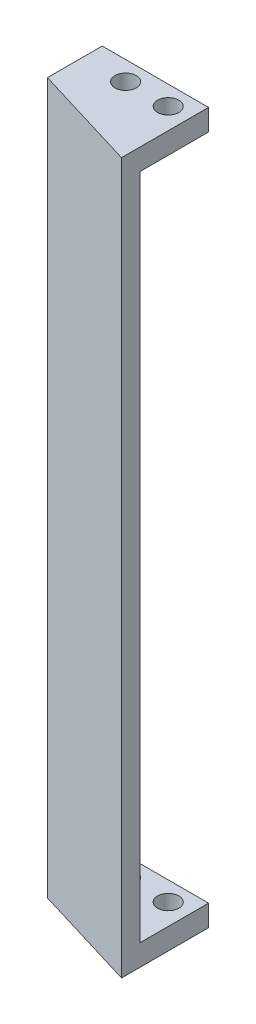
from build123d import *

# Parameters (mm, degrees)
SKETCH1_R           = 1.5
BOSS_EXTRUDE1_DEPTH = 3
BOSS_EXTRUDE2_DEPTH = 94


with BuildPart() as part:
    # Sketch1 → Boss-Extrude1 (new body)
    with BuildSketch(Plane(origin=(0, 0, 0), x_dir=(1, 0, 0), z_dir=(0, 1, 0))):
        Polygon((-51.61867002, -8.75119844), (-51.61867002, 3.502641742), (-66.587954735, 3.502641742), (-66.587954735, -4.206262026), align=None)
        with Locations((-54.587954735, 0.793737974)):
            Circle(SKETCH1_R, mode=Mode.SUBTRACT)
        with Locations((-60.587954735, 0.793737974)):
            Circle(SKETCH1_R, mode=Mode.SUBTRACT)
    boss_extrude1 = extrude(amount=BOSS_EXTRUDE1_DEPTH)

    # Sketch2 → Boss-Extrude2 (add)
    with BuildSketch(Plane(origin=(0, 3, 0), x_dir=(1, 0, 0), z_dir=(0, 1, 0))):
        Polygon((-64.087954735, 3.502641742), (-66.587954735, 3.502641742), (-66.587954735, -4.206262026), (-63.361180244, -5.185967146), (-61.932848842, -5.619633518), (-51.61867002, -8.75119844), (-51.61867002, -6.138508769), (-61.92070968, -3.010629509), (-64.087954735, -2.35261604), align=None)
    extrude(amount=BOSS_EXTRUDE2_DEPTH)

    # Mirror1: Boss-Extrude1 across plane
    add(boss_extrude1.mirror(Plane(origin=(0, 50, 0), x_dir=(0, 0, 1), z_dir=(0, -1, 0))))


solid = part.part
